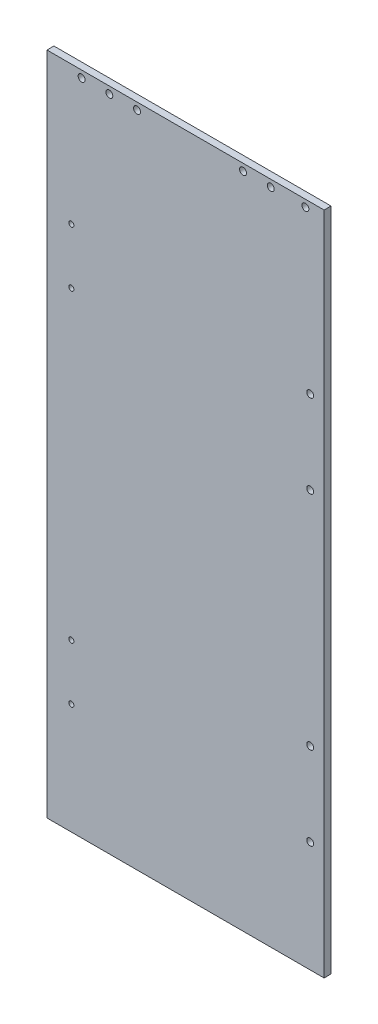
from build123d import *

# Parameters (mm, degrees)
SKETCH1_W           = 254
SKETCH1_H           = 609.6
BOSS_EXTRUDE1_DEPTH = 6.35
SKETCH2_R           = 2.38125
CUT_EXTRUDE1_DEPTH  = 7.35
SKETCH3_R           = 3.175
CUT_EXTRUDE2_DEPTH  = 7.35
SKETCH4_R           = 3.175
CUT_EXTRUDE3_DEPTH  = 7.35


with BuildPart() as part:
    # Sketch1 → Boss-Extrude1 (new body)
    with BuildSketch(Plane.XY):
        with Locations((98.425, -304.8)):
            Rectangle(SKETCH1_W, SKETCH1_H)
    extrude(amount=BOSS_EXTRUDE1_DEPTH)

    # Sketch2 → Cut-Extrude1 (cut, through all)
    with BuildSketch(Plane.XY.offset(6.35)):
        with Locations((-6.223, -127)):
            Circle(SKETCH2_R)
        with Locations((-6.223, -177.8)):
            Circle(SKETCH2_R)
        with Locations((-6.223, -457.2)):
            Circle(SKETCH2_R)
        with Locations((-6.223, -508)):
            Circle(SKETCH2_R)
    extrude(amount=-CUT_EXTRUDE1_DEPTH, mode=Mode.SUBTRACT)

    # Sketch3 → Cut-Extrude2 (cut, through all)
    with BuildSketch(Plane(origin=(0, 0, 0), x_dir=(-1, 0, 0), z_dir=(0, 0, -1))):
        with Locations((-208.28, -6.35)):
            Circle(SKETCH3_R)
        with Locations((-176.53, -6.35)):
            Circle(SKETCH3_R)
        with Locations((-151.13, -6.35)):
            Circle(SKETCH3_R)
        with Locations((-53.975, -6.35)):
            Circle(SKETCH3_R)
        with Locations((-28.575, -6.35)):
            Circle(SKETCH3_R)
        with Locations((-3.175, -6.35)):
            Circle(SKETCH3_R)
    extrude(amount=-CUT_EXTRUDE2_DEPTH, mode=Mode.SUBTRACT)

    # Sketch4 → Cut-Extrude3 (cut, through all)
    with BuildSketch(Plane.XY.offset(6.35)):
        with Locations((212.706676403, -431.8)):
            Circle(SKETCH4_R)
        with Locations((212.706676403, -508)):
            Circle(SKETCH4_R)
        with Locations((212.706676403, -228.6)):
            Circle(SKETCH4_R)
        with Locations((212.706676403, -152.4)):
            Circle(SKETCH4_R)
    extrude(amount=-CUT_EXTRUDE3_DEPTH, mode=Mode.SUBTRACT)


solid = part.part
